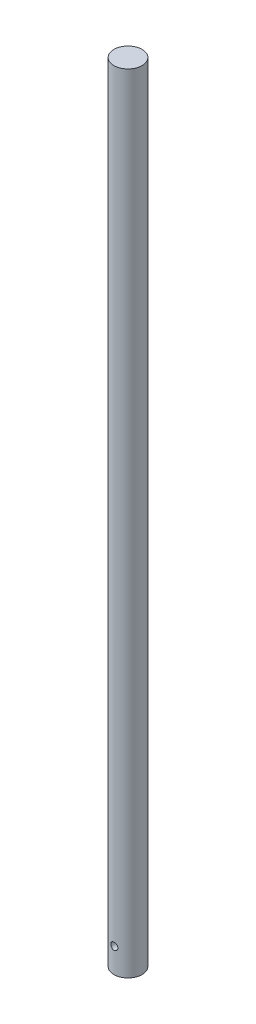
from build123d import *

# Parameters (mm, degrees)
SKETCH1_R               = 6.35
BOSS_EXTRUDE1_DEPTH     = 177.8
SKETCH2_R               = 1.5875
CUT_EXTRUDE1_DEPTH      = 7.35
CUT_EXTRUDE1_DEPTH_BACK = 7.35


with BuildPart() as part:
    # Sketch1 → Boss-Extrude1 (new body, symmetric)
    with BuildSketch(Plane(origin=(0, 0, 0), x_dir=(1, 0, 0), z_dir=(0, 1, 0))):
        Circle(SKETCH1_R)
    extrude(amount=BOSS_EXTRUDE1_DEPTH, both=True)

    # Sketch2 → Cut-Extrude1 (cut, two sides)
    with BuildSketch(Plane.XY) as cut_extrude1_sk:
        with Locations((0, -166.6875)):
            Circle(SKETCH2_R)
    extrude(amount=CUT_EXTRUDE1_DEPTH, mode=Mode.SUBTRACT)
    extrude(cut_extrude1_sk.sketch, amount=-CUT_EXTRUDE1_DEPTH_BACK, mode=Mode.SUBTRACT)


solid = part.part
